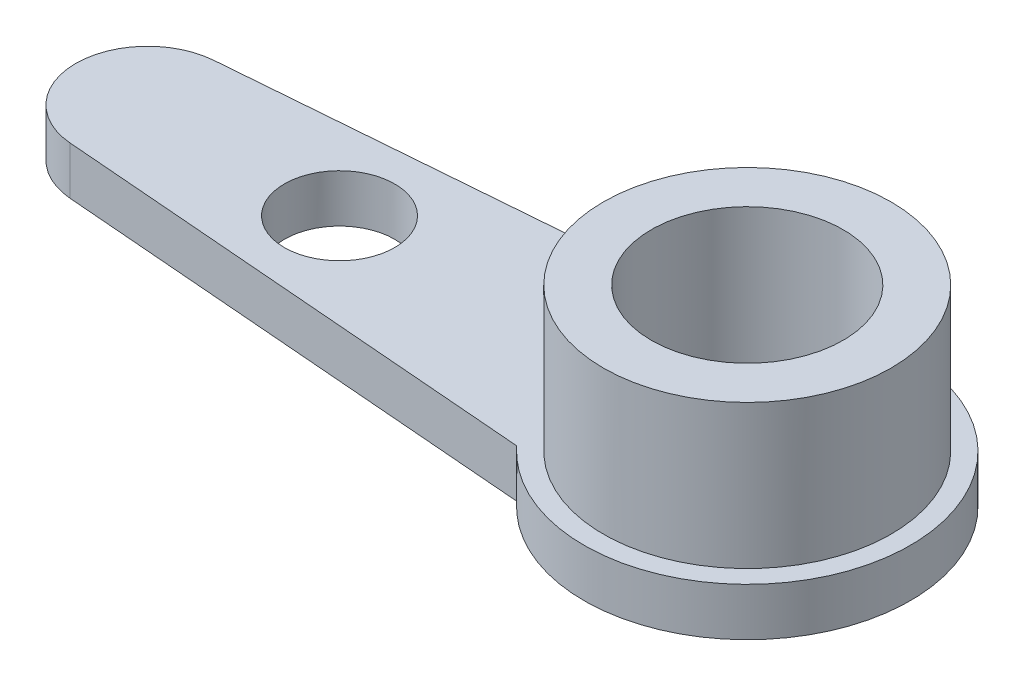
from build123d import *

# Parameters (mm, degrees)
SKICA1_R                 = 2
P_IDAT_VYSUNUT_M1_DEPTH  = 1
SKICA2_R                 = 1.15
ODEBRAT_VYSUNUT_M1_DEPTH = 2
SKICA3_R                 = 3
SKICA3_R_2               = 2
P_IDAT_VYSUNUT_M2_DEPTH  = 3
ODEBRAT_VYSUNUT_M2_DEPTH = 10


with BuildPart() as part:
    # Skica1 → Přidat vysunutím1 (new body)
    with BuildSketch(Plane(origin=(0, 0, 0), x_dir=(1, 0, 0), z_dir=(0, 1, 0))):
        with BuildLine():
            Line((-12.62, 1.495192295), (-2.5, 2.307395517))
            Line((-2.5, 2.307395517), (-2.5, 5.25))
            ThreePointArc((-2.5, 5.25), (0, 7.75), (2.5, 5.25))
            Line((2.5, 5.25), (2.5, 2.307395517))
            Line((2.5, 2.307395517), (12.62, 1.495192295))
            ThreePointArc((12.62, 1.495192295), (14, 0), (12.62, -1.495192295))
            Line((12.62, -1.495192295), (2.5, -2.307395517))
            Line((2.5, -2.307395517), (2.5, -5.25))
            ThreePointArc((2.5, -5.25), (0, -7.75), (-2.5, -5.25))
            Line((-2.5, -5.25), (-2.5, -2.307395517))
            Line((-2.5, -2.307395517), (-12.62, -1.495192295))
            ThreePointArc((-12.62, -1.495192295), (-14, 0), (-12.62, 1.495192295))
        make_face()
        Circle(SKICA1_R, mode=Mode.SUBTRACT)
    extrude(amount=P_IDAT_VYSUNUT_M1_DEPTH)

    # Skica2 → Odebrat vysunutím1 (cut)
    with BuildSketch(Plane(origin=(0, 1, 0), x_dir=(1, 0, 0), z_dir=(0, 1, 0))):
        with Locations((-8.5, 0)):
            Circle(SKICA2_R)
        with Locations((8.5, 0)):
            Circle(SKICA2_R)
    extrude(amount=-ODEBRAT_VYSUNUT_M1_DEPTH, mode=Mode.SUBTRACT)

    # Skica3 → Přidat vysunutím2 (add)
    with BuildSketch(Plane(origin=(0, 1, 0), x_dir=(1, 0, 0), z_dir=(0, 1, 0))):
        Circle(SKICA3_R)
        Circle(SKICA3_R_2, mode=Mode.SUBTRACT)
    extrude(amount=P_IDAT_VYSUNUT_M2_DEPTH)

    # Skica4 → Odebrat vysunutím2 (cut)
    with BuildSketch(Plane.XZ):
        with BuildLine():
            Line((-2.5, 2.307395517), (-2.5, 10.588101579))
            Line((-2.5, 10.588101579), (18.005147354, 10.588101579))
            Line((18.005147354, 10.588101579), (18.005147354, -8.717716122))
            Line((18.005147354, -8.717716122), (-2.5, -8.868206906))
            Line((-2.5, -8.868206906), (-2.5, -2.307395517))
            ThreePointArc((-2.5, -2.307395517), (3.402069087, 0), (-2.5, 2.307395517))
        make_face()
    extrude(amount=-ODEBRAT_VYSUNUT_M2_DEPTH, mode=Mode.SUBTRACT)


solid = part.part
